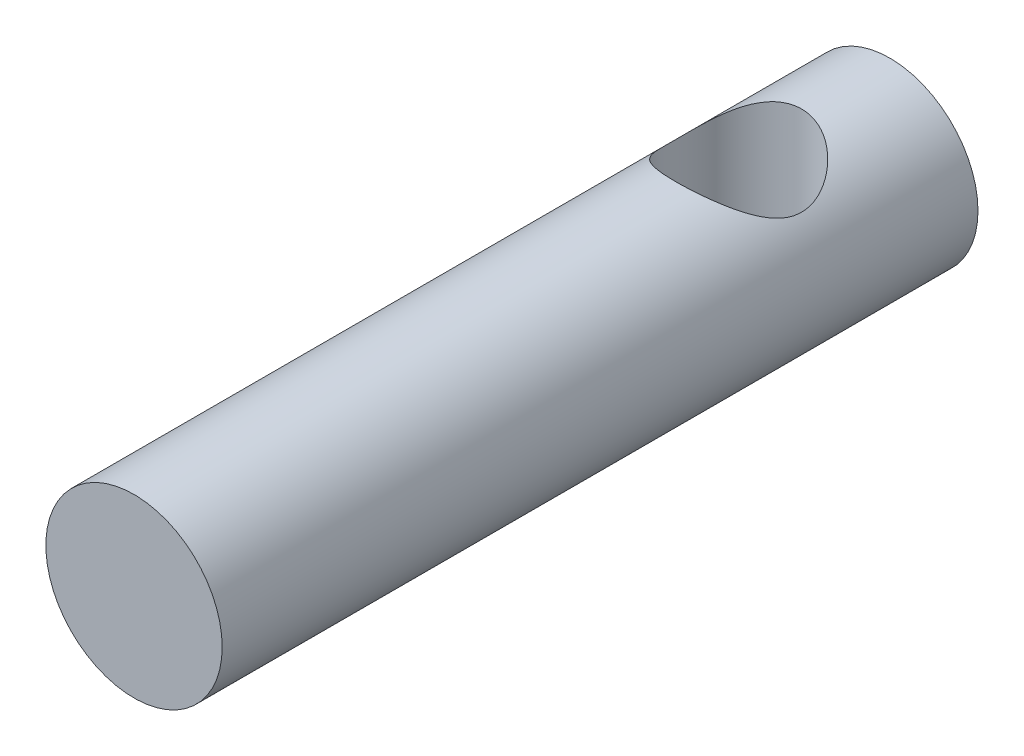
from build123d import *

# Parameters (mm, degrees)
SKETCH1_R               = 1.75
BOSS_EXTRUDE1_DEPTH     = 15
SKETCH2_R               = 1.25
CUT_EXTRUDE1_DEPTH      = 3.363841026
CUT_EXTRUDE1_DEPTH_BACK = 2.136158974


with BuildPart() as part:
    # Sketch1 → Boss-Extrude1 (new body)
    with BuildSketch(Plane.XY):
        with Locations((0.656667144, 0.613841026)):
            Circle(SKETCH1_R)
    extrude(amount=BOSS_EXTRUDE1_DEPTH)

    # Sketch2 → Cut-Extrude1 (cut, two sides)
    with BuildSketch(Plane(origin=(0, 0, 0), x_dir=(1, 0, 0), z_dir=(0, 1, 0))) as cut_extrude1_sk:
        with Locations((0.656667144, -3)):
            Circle(SKETCH2_R)
    extrude(amount=CUT_EXTRUDE1_DEPTH, mode=Mode.SUBTRACT)
    extrude(cut_extrude1_sk.sketch, amount=-CUT_EXTRUDE1_DEPTH_BACK, mode=Mode.SUBTRACT)


solid = part.part
